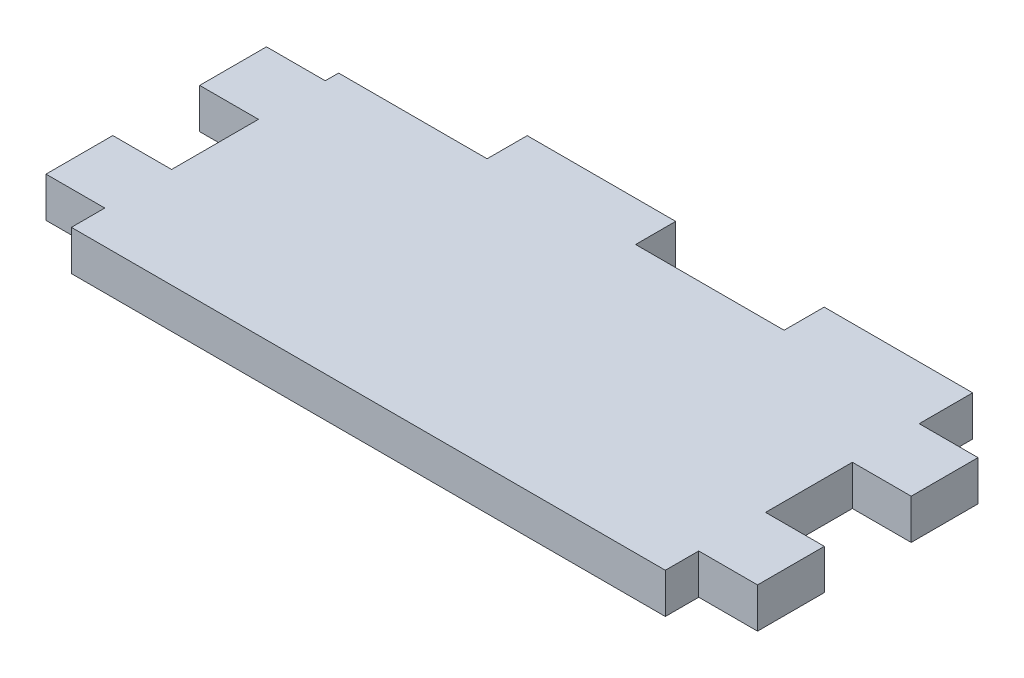
from build123d import *

# Parameters (mm, degrees)
BOSS_EXTRUDE1_DEPTH = 3
SKETCH2_W           = 11.1125
SKETCH2_H           = 3
CUT_EXTRUDE1_DEPTH  = 4


with BuildPart() as part:
    # Sketch1 → Boss-Extrude1 (new body)
    with BuildSketch(Plane(origin=(0, 0, 0), x_dir=(1, 0, 0), z_dir=(0, 1, 0))):
        Polygon((-22.225, -11.5), (22.225, -11.5), (22.225, -9), (26.625, -9), (26.625, -4), (22.225, -4), (22.225, 2.5), (26.625, 2.5), (26.625, 7.5), (22.225, 7.5), (22.225, 11.5), (-22.225, 11.5), (-22.225, 7.5), (-26.625, 7.5), (-26.625, 2.5), (-22.225, 2.5), (-22.225, -4), (-26.625, -4), (-26.625, -9), (-22.225, -9), align=None)
    extrude(amount=BOSS_EXTRUDE1_DEPTH)

    # Sketch2 → Cut-Extrude1 (cut, through all)
    with BuildSketch(Plane(origin=(0, 3, 0), x_dir=(1, 0, 0), z_dir=(0, 1, 0))):
        with Locations((-16.66875, 10)):
            Rectangle(SKETCH2_W, SKETCH2_H)
        with Locations((5.55625, 10)):
            Rectangle(SKETCH2_W, SKETCH2_H)
    extrude(amount=-CUT_EXTRUDE1_DEPTH, mode=Mode.SUBTRACT)


solid = part.part
